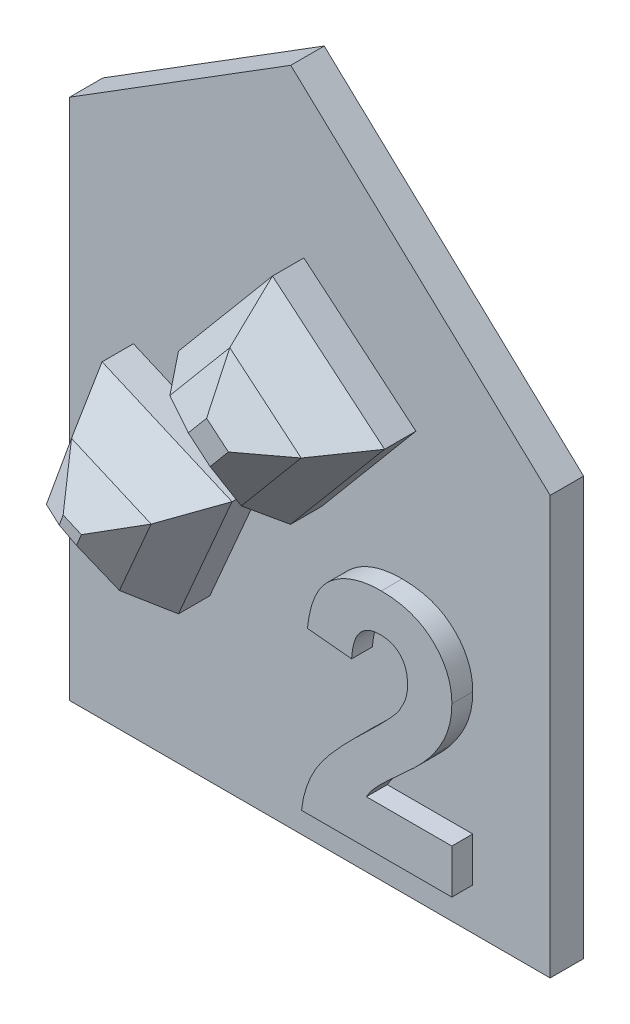
from build123d import *

# Parameters (mm, degrees)
P_IDAT_VYSUNUT_M5_DEPTH = 1.6
P_IDAT_VYSUNUT_M6_DEPTH = 1
P_IDAT_VYSUNUT_M7_DEPTH = 5
ZKOSEN_1_SIZE           = 3.5
ZKOSEN_1_SIZE2          = 2.020725942
ZKOSEN_1_PART_2_SIZE    = 3.5
ZKOSEN_1_PART_2_SIZE2   = 2.020725942
ZKOSEN_1_PART_3_SIZE    = 3.5
ZKOSEN_1_PART_3_SIZE2   = 2.020725942
ZKOSEN_1_PART_4_SIZE    = 3.5
ZKOSEN_1_PART_4_SIZE2   = 2.020725942
ZKOSEN_1_PART_5_SIZE    = 3.5
ZKOSEN_1_PART_5_SIZE2   = 2.020725942
ZKOSEN_1_PART_6_SIZE    = 3.5
ZKOSEN_1_PART_6_SIZE2   = 2.020725942
ZKOSEN_1_PART_7_SIZE    = 3.5
ZKOSEN_1_PART_7_SIZE2   = 2.020725942
ZKOSEN_1_PART_8_SIZE    = 3.5
ZKOSEN_1_PART_8_SIZE2   = 2.020725942
ZKOSEN_2_SIZE           = 1.5
ZKOSEN_2_SIZE2          = 0.798133329
ZKOSEN_2_PART_2_SIZE    = 1.5
ZKOSEN_2_PART_2_SIZE2   = 0.798133329
ZKOSEN_2_PART_3_SIZE    = 1.5
ZKOSEN_2_PART_3_SIZE2   = 0.798133329
ZKOSEN_2_PART_4_SIZE    = 1.5
ZKOSEN_2_PART_4_SIZE2   = 0.798133329
ZKOSEN_2_PART_5_SIZE    = 1.5
ZKOSEN_2_PART_5_SIZE2   = 0.798133329
ZKOSEN_2_PART_6_SIZE    = 1.5
ZKOSEN_2_PART_6_SIZE2   = 0.798133329
ZKOSEN_2_PART_7_SIZE    = 1.5
ZKOSEN_2_PART_7_SIZE2   = 0.798133329
ZKOSEN_2_PART_8_SIZE    = 1.5
ZKOSEN_2_PART_8_SIZE2   = 0.798133329


with BuildPart() as part:
    # Skica1 → Přidat vysunutím5 (new body)
    with BuildSketch(Plane.XY):
        Polygon((0, 0), (0, 20), (-12.412784718, 31.615626352), (-23, 25), (-23, 0), align=None)
    extrude(amount=P_IDAT_VYSUNUT_M5_DEPTH)

    # Skica2 → Přidat vysunutím6 (add)
    with BuildSketch(Plane.XY.offset(1.6)):
        with BuildLine():
            Line((-3.705128205, 4.115384615), (-3.705128205, 2))
            Line((-3.705128205, 2), (-10.897435897, 2))
            add(Edge.make_bspline(
                [(-10.897435897, 2), (-10.87308441, 2.180790308), (-10.824395089, 2.542269551), (-10.673865117, 3.070299742), (-10.472959166, 3.585566992), (-10.254913916, 4.004869463), (-10.038043764, 4.342393523), (-9.841277463, 4.618963346), (-9.60654249, 4.913221767), (-9.337245105, 5.227544267), (-9.034873554, 5.562913411), (-8.697171951, 5.918082368), (-8.322529407, 6.291350846), (-8.058961705, 6.54481851), (-7.922676282, 6.67588141)],
                knots=[0, 0, 0, 0, 0.000546661, 0.001093015, 0.001642153, 0.002203944, 0.002507135, 0.00284526, 0.003221747, 0.003635945, 0.00408685, 0.004576261, 0.005106025, 0.00567326, 0.00567326, 0.00567326, 0.00567326], degree=3))
            add(Edge.make_bspline(
                [(-7.922676282, 6.67588141), (-7.813918956, 6.780862005), (-7.606877039, 6.980714138), (-7.312048947, 7.266894293), (-7.052864674, 7.529975199), (-6.823905036, 7.763139303), (-6.630459323, 7.972323552), (-6.469982936, 8.154242742), (-6.34044346, 8.309637702), (-6.270284768, 8.408220362), (-6.239182692, 8.451923077)],
                knots=[0, 0, 0, 0, 0.000453482, 0.000863296, 0.001232576, 0.001561374, 0.001843606, 0.002087173, 0.00228919, 0.002450062, 0.002450062, 0.002450062, 0.002450062], degree=3))
            add(Edge.make_bspline(
                [(-6.239182692, 8.451923077), (-6.175493233, 8.557718073), (-6.052643645, 8.761784362), (-5.91792888, 9.082682292), (-5.837068057, 9.403513936), (-5.825971765, 9.617891805), (-5.820512821, 9.723357372)],
                knots=[0, 0, 0, 0, 0.000370068, 0.000713818, 0.001040364, 0.001356575, 0.001356575, 0.001356575, 0.001356575], degree=3))
            add(Edge.make_bspline(
                [(-5.820512821, 9.723357372), (-5.824474653, 9.833108474), (-5.831970132, 10.040748999), (-5.894821019, 10.333768175), (-6.006276867, 10.585659667), (-6.15973106, 10.797196661), (-6.353774193, 10.962935085), (-6.580616259, 11.085399693), (-6.843577862, 11.153106661), (-7.028402789, 11.16201224), (-7.125, 11.166666667)],
                knots=[0, 0, 0, 0, 0.000329064, 0.000622563, 0.000892834, 0.001149779, 0.00139978, 0.001652148, 0.001916728, 0.002206405, 0.002206405, 0.002206405, 0.002206405], degree=3))
            add(Edge.make_bspline(
                [(-7.125, 11.166666667), (-7.220944609, 11.16231978), (-7.406288878, 11.153922533), (-7.669703299, 11.080565334), (-7.900142302, 10.953576306), (-8.06436539, 10.808860058), (-8.175305876, 10.668134018), (-8.250896853, 10.545500545), (-8.316050374, 10.406151312), (-8.37378183, 10.251655158), (-8.419383153, 10.080242168), (-8.456107626, 9.893217825), (-8.485702239, 9.689575671), (-8.495113848, 9.547907653), (-8.5, 9.474358974)],
                knots=[0, 0, 0, 0, 0.000287482, 0.000555353, 0.000811759, 0.001070877, 0.001205779, 0.00134826, 0.001502018, 0.001666561, 0.00184243, 0.002033439, 0.002238177, 0.002459233, 0.002459233, 0.002459233, 0.002459233], degree=3))
            Line((-8.5, 9.474358974), (-10.615384615, 9.681490385))
            add(Edge.make_bspline(
                [(-10.615384615, 9.681490385), (-10.598377251, 9.824305509), (-10.565402688, 10.101201217), (-10.483114114, 10.498918926), (-10.378898684, 10.865831465), (-10.247788098, 11.201257911), (-10.095201314, 11.507331251), (-9.913355139, 11.779458664), (-9.708603468, 12.020654551), (-9.480769352, 12.230790543), (-9.231301205, 12.410535137), (-8.969529148, 12.57098477), (-8.690337423, 12.702604473), (-8.396799939, 12.811078884), (-8.089049352, 12.897770766), (-7.765662274, 12.955090263), (-7.42863453, 12.995409017), (-7.198577984, 12.998446608), (-7.080929487, 13)],
                knots=[0, 0, 0, 0, 0.000431306, 0.000836233, 0.001217004, 0.001574233, 0.001915203, 0.002240945, 0.002553567, 0.002862328, 0.003168197, 0.003474678, 0.003782194, 0.004092453, 0.004412693, 0.004739863, 0.005076887, 0.005429623, 0.005429623, 0.005429623, 0.005429623], degree=3))
            add(Edge.make_bspline(
                [(-7.080929487, 13), (-6.953030371, 12.997541845), (-6.703930784, 12.992754281), (-6.34028961, 12.953218534), (-5.998674853, 12.884282231), (-5.676099879, 12.79296634), (-5.375877361, 12.67105295), (-5.095505554, 12.52366473), (-4.83939702, 12.345207999), (-4.603734114, 12.145414763), (-4.393070332, 11.925706984), (-4.20854792, 11.691351493), (-4.053955652, 11.442511564), (-3.924228998, 11.182220281), (-3.827907833, 10.90628918), (-3.757724044, 10.618533633), (-3.711189366, 10.317611197), (-3.707170936, 10.112088), (-3.705128205, 10.007612179)],
                knots=[0, 0, 0, 0, 0.000383641, 0.00074719, 0.0010955, 0.001428145, 0.001751403, 0.002065859, 0.002376361, 0.002685876, 0.002991333, 0.003287991, 0.003579024, 0.003868752, 0.004158681, 0.00445369, 0.004756592, 0.005069772, 0.005069772, 0.005069772, 0.005069772], degree=3))
            add(Edge.make_bspline(
                [(-3.705128205, 10.007612179), (-3.707819477, 9.887707131), (-3.713158546, 9.649833916), (-3.764276175, 9.298186238), (-3.84237396, 8.954647512), (-3.957796338, 8.618378159), (-4.104103161, 8.28131186), (-4.292696164, 7.942692037), (-4.511666905, 7.592306518), (-4.683112364, 7.36576699), (-4.771634615, 7.248798077)],
                knots=[0, 0, 0, 0, 0.000359506, 0.000713204, 0.001063842, 0.00141504, 0.001778167, 0.002164709, 0.002576738, 0.003016589, 0.003016589, 0.003016589, 0.003016589], degree=3))
            add(Edge.make_bspline(
                [(-4.771634615, 7.248798077), (-4.80509214, 7.206658226), (-4.876750403, 7.116404431), (-4.998659939, 6.978014195), (-5.139942605, 6.826848432), (-5.298602846, 6.660077667), (-5.479881522, 6.483607708), (-5.677256214, 6.290058721), (-5.899411985, 6.089331377), (-6.12951153, 5.876418507), (-6.360611244, 5.669193404), (-6.5730252, 5.472375498), (-6.765967752, 5.298233923), (-6.930453202, 5.137155265), (-7.076156545, 5.000133027), (-7.197826149, 4.880140867), (-7.29773874, 4.780083699), (-7.43541186, 4.624119958), (-7.610585282, 4.413178934), (-7.733826947, 4.21161882), (-7.792668269, 4.115384615)],
                knots=[0, 0, 0, 0, 0.0001614, 0.000345681, 0.000553058, 0.000782151, 0.00103613, 0.001311959, 0.001611379, 0.001934216, 0.002252456, 0.002542536, 0.002802971, 0.003032064, 0.003233117, 0.00340296, 0.003544758, 0.003657116, 0.004027059, 0.004365069, 0.004365069, 0.004365069, 0.004365069], degree=3))
            Line((-7.792668269, 4.115384615), (-3.705128205, 4.115384615))
        make_face()
    extrude(amount=P_IDAT_VYSUNUT_M6_DEPTH)

    # Skica3 → Přidat vysunutím7 (add)
    with BuildSketch(Plane.XY.offset(1.6)):
        Polygon((-10.923902938, 14.085251037), (-6.42438967, 19.447562139), (-11.786700772, 23.947075407), (-16.28621404, 18.584764305), align=None)
        Polygon((-16.28621404, 7.694697517), (-13.722737722, 13.627013902), (-19.940805957, 16.31396949), (-21.976156172, 10.660855709), align=None)
    extrude(amount=P_IDAT_VYSUNUT_M7_DEPTH)

    # Zkosení1
    zkosen_1_edges = [part.edges().sort_by_distance(p)[0] for p in [
        (-13.605058489, 16.335007671, 6.6),
    ]]
    zkosen_1_side = [part.faces().sort_by_distance(p)[0] for p in [
        (-13.605058489, 16.335007671, 4.1),
    ]]
    chamfer(zkosen_1_edges, length=ZKOSEN_1_SIZE, length2=ZKOSEN_1_SIZE2, reference=zkosen_1_side[0])

    # Zkosení1 part 2
    zkosen_1_part_2_edges = [part.edges().sort_by_distance(p)[0] for p in [
        (-8.674146304, 16.766406588, 6.6),
    ]]
    zkosen_1_part_2_side = [part.faces().sort_by_distance(p)[0] for p in [
        (-8.674146304, 16.766406588, 4.1),
    ]]
    chamfer(zkosen_1_part_2_edges, length=ZKOSEN_1_PART_2_SIZE, length2=ZKOSEN_1_PART_2_SIZE2, reference=zkosen_1_part_2_side[0])

    # Zkosení1 part 3
    zkosen_1_part_3_edges = [part.edges().sort_by_distance(p)[0] for p in [
        (-9.105545221, 21.697318773, 6.6),
    ]]
    zkosen_1_part_3_side = [part.faces().sort_by_distance(p)[0] for p in [
        (-9.105545221, 21.697318773, 4.1),
    ]]
    chamfer(zkosen_1_part_3_edges, length=ZKOSEN_1_PART_3_SIZE, length2=ZKOSEN_1_PART_3_SIZE2, reference=zkosen_1_part_3_side[0])

    # Zkosení1 part 4
    zkosen_1_part_4_edges = [part.edges().sort_by_distance(p)[0] for p in [
        (-14.036457406, 21.265919856, 6.6),
    ]]
    zkosen_1_part_4_side = [part.faces().sort_by_distance(p)[0] for p in [
        (-14.036457406, 21.265919856, 4.1),
    ]]
    chamfer(zkosen_1_part_4_edges, length=ZKOSEN_1_PART_4_SIZE, length2=ZKOSEN_1_PART_4_SIZE2, reference=zkosen_1_part_4_side[0])

    # Zkosení1 part 5
    zkosen_1_part_5_edges = [part.edges().sort_by_distance(p)[0] for p in [
        (-19.131185106, 9.177776613, 6.6),
    ]]
    zkosen_1_part_5_side = [part.faces().sort_by_distance(p)[0] for p in [
        (-19.131185106, 9.177776613, 4.1),
    ]]
    chamfer(zkosen_1_part_5_edges, length=ZKOSEN_1_PART_5_SIZE, length2=ZKOSEN_1_PART_5_SIZE2, reference=zkosen_1_part_5_side[0])

    # Zkosení1 part 6
    zkosen_1_part_6_edges = [part.edges().sort_by_distance(p)[0] for p in [
        (-15.004475881, 10.660855709, 6.6),
    ]]
    zkosen_1_part_6_side = [part.faces().sort_by_distance(p)[0] for p in [
        (-15.004475881, 10.660855709, 4.1),
    ]]
    chamfer(zkosen_1_part_6_edges, length=ZKOSEN_1_PART_6_SIZE, length2=ZKOSEN_1_PART_6_SIZE2, reference=zkosen_1_part_6_side[0])

    # Zkosení1 part 7
    zkosen_1_part_7_edges = [part.edges().sort_by_distance(p)[0] for p in [
        (-16.831771839, 14.970491696, 6.6),
    ]]
    zkosen_1_part_7_side = [part.faces().sort_by_distance(p)[0] for p in [
        (-16.831771839, 14.970491696, 4.1),
    ]]
    chamfer(zkosen_1_part_7_edges, length=ZKOSEN_1_PART_7_SIZE, length2=ZKOSEN_1_PART_7_SIZE2, reference=zkosen_1_part_7_side[0])

    # Zkosení1 part 8
    zkosen_1_part_8_edges = [part.edges().sort_by_distance(p)[0] for p in [
        (-20.958481064, 13.4874126, 6.6),
    ]]
    zkosen_1_part_8_side = [part.faces().sort_by_distance(p)[0] for p in [
        (-20.958481064, 13.4874126, 4.1),
    ]]
    chamfer(zkosen_1_part_8_edges, length=ZKOSEN_1_PART_8_SIZE, length2=ZKOSEN_1_PART_8_SIZE2, reference=zkosen_1_part_8_side[0])

    # Zkosení2
    zkosen_2_edges = [part.edges().sort_by_distance(p)[0] for p in [
        (-16.829194071, 11.532374342, 6.6),
    ]]
    zkosen_2_side = [part.faces().sort_by_distance(p)[0] for p in [
        (-15.77075521, 11.02684467, 4.569803757),
    ]]
    chamfer(zkosen_2_edges, length=ZKOSEN_2_SIZE, length2=ZKOSEN_2_SIZE2, reference=zkosen_2_side[0])

    # Zkosení2 part 2
    zkosen_2_part_2_edges = [part.edges().sort_by_distance(p)[0] for p in [
        (-17.573678925, 13.089765682, 6.6),
    ]]
    zkosen_2_part_2_side = [part.faces().sort_by_distance(p)[0] for p in [
        (-17.147713244, 14.169583833, 4.590476284),
    ]]
    chamfer(zkosen_2_part_2_edges, length=ZKOSEN_2_PART_2_SIZE, length2=ZKOSEN_2_PART_2_SIZE2, reference=zkosen_2_part_2_side[0])

    # Zkosení2 part 3
    zkosen_2_part_3_edges = [part.edges().sort_by_distance(p)[0] for p in [
        (-19.122574482, 12.621393223, 6.6),
    ]]
    zkosen_2_part_3_side = [part.faces().sort_by_distance(p)[0] for p in [
        (-20.188422633, 13.124166708, 4.568051009),
    ]]
    chamfer(zkosen_2_part_3_edges, length=ZKOSEN_2_PART_3_SIZE, length2=ZKOSEN_2_PART_3_SIZE2, reference=zkosen_2_part_3_side[0])

    # Zkosení2 part 4
    zkosen_2_part_4_edges = [part.edges().sort_by_distance(p)[0] for p in [
        (-18.378089628, 11.064001883, 6.6),
    ]]
    zkosen_2_part_4_side = [part.faces().sort_by_distance(p)[0] for p in [
        (-18.810204822, 9.981713353, 4.591751084),
    ]]
    chamfer(zkosen_2_part_4_edges, length=ZKOSEN_2_PART_4_SIZE, length2=ZKOSEN_2_PART_4_SIZE2, reference=zkosen_2_part_4_side[0])

    # Zkosení2 part 5
    zkosen_2_part_5_edges = [part.edges().sort_by_distance(p)[0] for p in [
        (-10.404442819, 20.149352894, 6.6),
    ]]
    zkosen_2_part_5_side = [part.faces().sort_by_distance(p)[0] for p in [
        (-9.66713931, 21.028037, 4.613267339),
    ]]
    chamfer(zkosen_2_part_5_edges, length=ZKOSEN_2_PART_5_SIZE, length2=ZKOSEN_2_PART_5_SIZE2, reference=zkosen_2_part_5_side[0])

    # Zkosení2 part 6
    zkosen_2_part_6_edges = [part.edges().sort_by_distance(p)[0] for p in [
        (-12.488491527, 19.967022258, 6.6),
    ]]
    zkosen_2_part_6_side = [part.faces().sort_by_distance(p)[0] for p in [
        (-13.367175633, 20.704325767, 4.613267339),
    ]]
    chamfer(zkosen_2_part_6_edges, length=ZKOSEN_2_PART_6_SIZE, length2=ZKOSEN_2_PART_6_SIZE2, reference=zkosen_2_part_6_side[0])

    # Zkosení2 part 7
    zkosen_2_part_7_edges = [part.edges().sort_by_distance(p)[0] for p in [
        (-12.30616089, 17.88297355, 6.6),
    ]]
    zkosen_2_part_7_side = [part.faces().sort_by_distance(p)[0] for p in [
        (-13.0434644, 17.004289444, 4.613267339),
    ]]
    chamfer(zkosen_2_part_7_edges, length=ZKOSEN_2_PART_7_SIZE, length2=ZKOSEN_2_PART_7_SIZE2, reference=zkosen_2_part_7_side[0])

    # Zkosení2 part 8
    zkosen_2_part_8_edges = [part.edges().sort_by_distance(p)[0] for p in [
        (-10.222112183, 18.065304186, 6.6),
    ]]
    zkosen_2_part_8_side = [part.faces().sort_by_distance(p)[0] for p in [
        (-9.343428077, 17.328000677, 4.613267339),
    ]]
    chamfer(zkosen_2_part_8_edges, length=ZKOSEN_2_PART_8_SIZE, length2=ZKOSEN_2_PART_8_SIZE2, reference=zkosen_2_part_8_side[0])


solid = part.part
